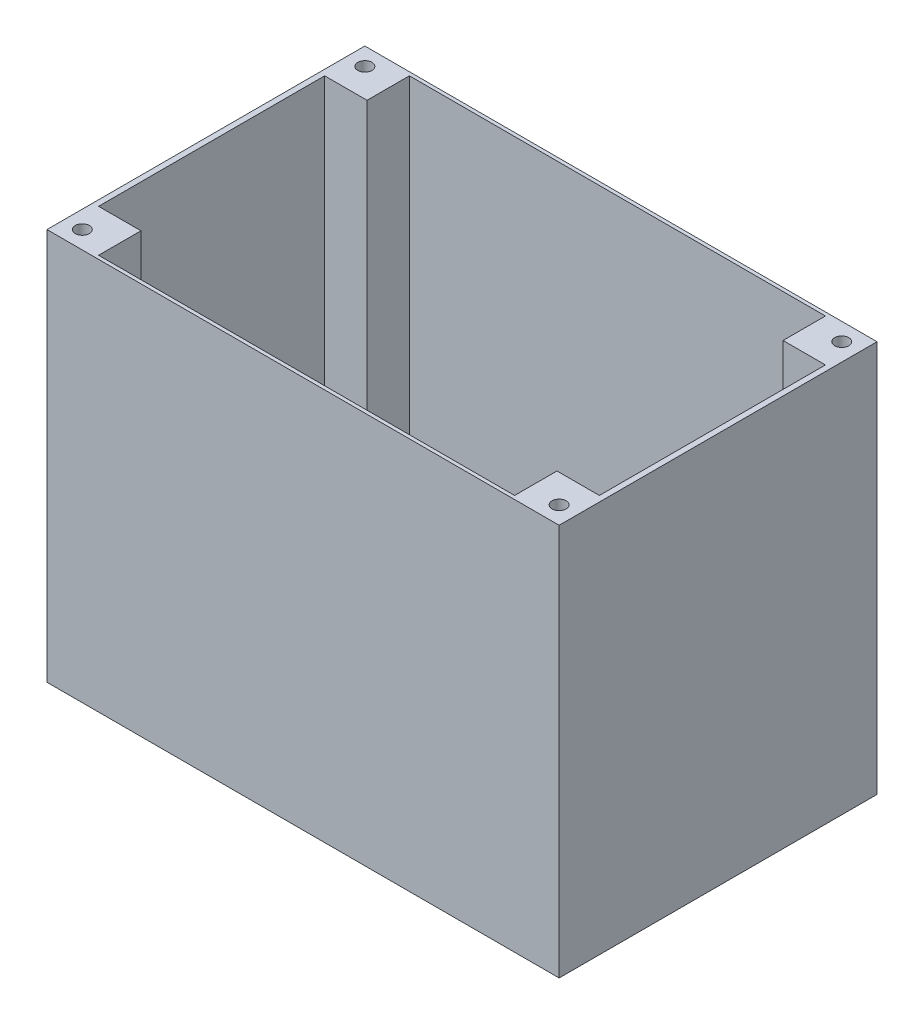
from build123d import *

# Parameters (mm, degrees)
SKETCH3_W           = 145
SKETCH3_H           = 90
SKETCH3_W_2         = 141.777777778
SKETCH3_H_2         = 88
BOSS_EXTRUDE1_DEPTH = 110
SKETCH4_W           = 145
SKETCH4_H           = 90
BOSS_EXTRUDE2_DEPTH = 1
SKETCH5_W           = 12
SKETCH5_H           = 12
BOSS_EXTRUDE3_DEPTH = 110
SKETCH6_R           = 2
CUT_EXTRUDE1_DEPTH  = 12
SKETCH7_R           = 10
CUT_EXTRUDE2_DEPTH  = 12


with BuildPart() as part:
    # Sketch3 → Boss-Extrude1 (new body)
    with BuildSketch(Plane(origin=(0, 0, 0), x_dir=(1, 0, 0), z_dir=(0, 1, 0))):
        Rectangle(SKETCH3_W, SKETCH3_H)
        Rectangle(SKETCH3_W_2, SKETCH3_H_2, mode=Mode.SUBTRACT)
    extrude(amount=BOSS_EXTRUDE1_DEPTH)

    # Sketch4 → Boss-Extrude2 (add)
    with BuildSketch(Plane.XZ):
        Rectangle(SKETCH4_W, SKETCH4_H)
    extrude(amount=BOSS_EXTRUDE2_DEPTH)

    # Sketch5 → Boss-Extrude3 (add)
    with BuildSketch(Plane(origin=(0, 0, 0), x_dir=(1, 0, 0), z_dir=(0, 1, 0))):
        with Locations((-64.888888889, 38)):
            Rectangle(SKETCH5_W, SKETCH5_H)
        with Locations((64.888888889, 38)):
            Rectangle(SKETCH5_W, SKETCH5_H)
        with Locations((64.888888889, -38)):
            Rectangle(SKETCH5_W, SKETCH5_H)
        with Locations((-64.888888889, -38)):
            Rectangle(SKETCH5_W, SKETCH5_H)
    extrude(amount=BOSS_EXTRUDE3_DEPTH)

    # Sketch6 → Cut-Extrude1 (cut)
    with BuildSketch(Plane(origin=(0, 110, 0), x_dir=(1, 0, 0), z_dir=(0, 1, 0))):
        with Locations((-67.5, 40)):
            Circle(SKETCH6_R)
        with Locations((-67.5, -40)):
            Circle(SKETCH6_R)
        with Locations((67.5, -40)):
            Circle(SKETCH6_R)
        with Locations((67.5, 40)):
            Circle(SKETCH6_R)
    extrude(amount=-CUT_EXTRUDE1_DEPTH, mode=Mode.SUBTRACT)

    # Sketch7 → Cut-Extrude2 (cut)
    with BuildSketch(Plane(origin=(0, 0, 0), x_dir=(1, 0, 0), z_dir=(0, 1, 0))):
        Circle(SKETCH7_R)
    extrude(amount=-CUT_EXTRUDE2_DEPTH, mode=Mode.SUBTRACT)


solid = part.part
